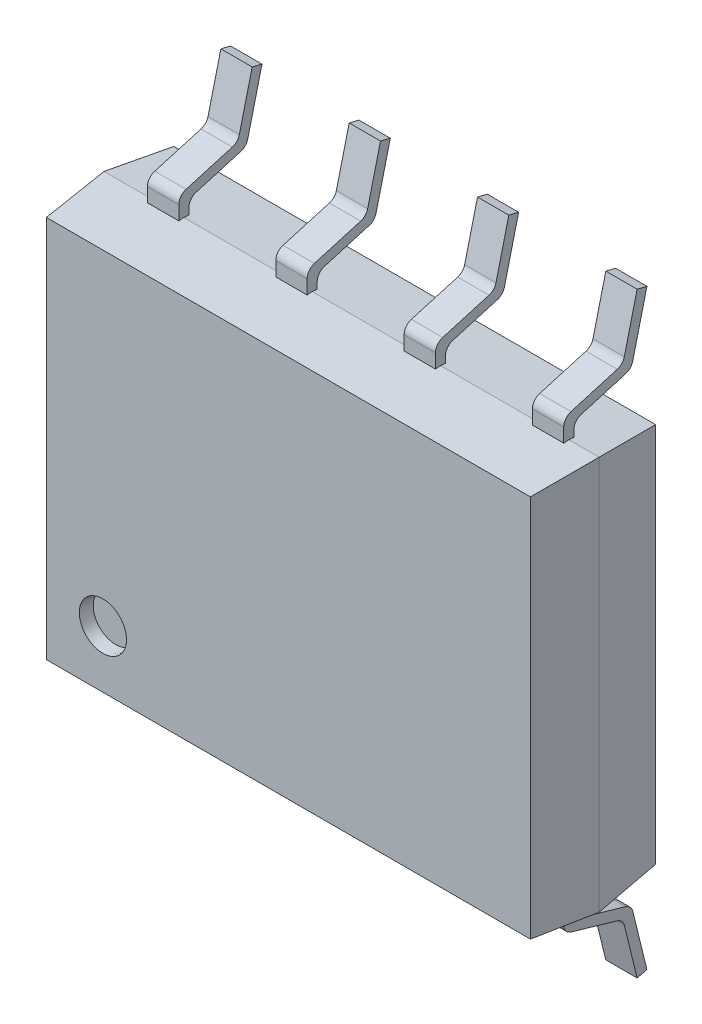
from build123d import *

# Parameters (mm, degrees)
SKETCH1_W            = 4.9
SKETCH1_H            = 3.8999999999999995
BOSS_EXTRUDE1_DEPTH  = 0.62500002
BOSS_EXTRUDE1_TAPER  = 5.000000000000003
SKETCH2_W            = 4.9
SKETCH2_H            = 3.8999999999999995
BOSS_EXTRUDE2_DEPTH  = 0.62500002
BOSS_EXTRUDE2_TAPER  = 6.000000000000002
SKETCH3_R            = 0.23364323022947278
CUT_EXTRUDE1_DEPTH   = 0.127
CUT_EXTRUDE1_DRAFT   = -5.000000000000003
EXTRUDE_THIN1_DEPTH  = 0.155
LPATTERN4_COUNT      = 4
LPATTERN4_PITCH      = 1.27
FILLET1_R            = 0.1
FILLET2_R            = 0.1
FILLET3_R            = 0.1
FILLET4_R            = 0.1
MIRROR3_COPY_1_DEPTH = 0.155
MIRROR3_COPY_2_DEPTH = 0.155
MIRROR3_COPY_3_DEPTH = 0.155
FILLET1_OF_MIRROR3_R = 0.1
FILLET2_OF_MIRROR3_R = 0.1
FILLET3_OF_MIRROR3_R = 0.1
FILLET4_OF_MIRROR3_R = 0.1


with BuildPart() as part:
    # Sketch1 → Boss-Extrude1 (new body)
    with BuildSketch(Plane.XY):
        with Locations((2.45, 1.9499999999999997)):
            Rectangle(SKETCH1_W, SKETCH1_H)
    extrude(amount=BOSS_EXTRUDE1_DEPTH, taper=BOSS_EXTRUDE1_TAPER)


with BuildPart() as body_2:
    # Sketch2 → Boss-Extrude2 (new body)
    with BuildSketch(Plane(origin=(0, 0, 0), x_dir=(-1, 0, 0), z_dir=(0, 0, -1))):
        with Locations((-2.45, 1.9499999999999997)):
            Rectangle(SKETCH2_W, SKETCH2_H)
    extrude(amount=BOSS_EXTRUDE2_DEPTH, taper=BOSS_EXTRUDE2_TAPER)


with BuildPart() as cut_extrude1_tool:
    # Sketch3 → Cut-Extrude1 (with draft: the straight prism first)
    with BuildSketch(Plane.XY.offset(0.62500002)):
        with Locations((0.6137796469189993, 0.6221262046182119)):
            Circle(SKETCH3_R)
    extrude(amount=-CUT_EXTRUDE1_DEPTH)
    # Cut-Extrude1: the draft: its side faces are tilted about the plane it starts from
    cut_extrude1_sides = [cut_extrude1_tool.faces().sort_by_distance(p)[0] for p in [
        (0.380136417, 0.622126205, 0.56150002),
    ]]
    draft(cut_extrude1_sides, Plane.XY.offset(0.62500002), CUT_EXTRUDE1_DRAFT)


with BuildPart() as part_1:
    add(part.part)

    # Cut-Extrude1: cut by cut_extrude1_tool
    add(cut_extrude1_tool.part, mode=Mode.SUBTRACT)


with BuildPart() as body_3:
    # Sketch4 → Extrude-Thin1 (new, symmetric)
    with BuildSketch(Plane(origin=(0.635, 0, 0), x_dir=(0, 0, -1), z_dir=(1, 0, 0))):
        Polygon((-0.05, 0), (-0.05, -0.30963709875086937), (0.5356753097129546, -0.47995675897337087), (0.6764487913860271, -1.0519489832234266), (0.7735512486139731, -1.0280510167765735), (0.618991733008682, -0.40004324102662947), (0.05, -0.23457531532057946), (0.05, 0), align=None)
    extrude_thin1 = extrude(amount=EXTRUDE_THIN1_DEPTH, both=True)

    # Fillet1
    fillet1_edges = [body_3.edges().sort_by_distance(p)[0] for p in [
        (0.635, -0.47995675897337087, -0.5356753097129546),
        (0.635, -0.30963709875086937, 0.05),
        (0.635, -0.23457531532057946, -0.05),
        (0.635, -0.40004324102662947, -0.618991733008682),
    ]]
    fillet(fillet1_edges, radius=FILLET1_R)


with BuildPart() as lpattern4_1:
    # LPattern4: pattern copy
    add(extrude_thin1.moved(Location(Vector(1, 0, 0) * (1 * LPATTERN4_PITCH))))

    # Fillet2
    fillet2_edges = [lpattern4_1.edges().sort_by_distance(p)[0] for p in [
        (1.905, -0.47995675897337087, -0.5356753097129546),
        (1.905, -0.30963709875086937, 0.05),
        (1.905, -0.23457531532057946, -0.05),
        (1.905, -0.40004324102662947, -0.618991733008682),
    ]]
    fillet(fillet2_edges, radius=FILLET2_R)


with BuildPart() as lpattern4_2:
    # LPattern4: pattern copy
    add(extrude_thin1.moved(Location(Vector(1, 0, 0) * (2 * LPATTERN4_PITCH))))

    # Fillet3
    fillet3_edges = [lpattern4_2.edges().sort_by_distance(p)[0] for p in [
        (3.175, -0.47995675897337087, -0.5356753097129546),
        (3.175, -0.30963709875086937, 0.05),
        (3.175, -0.23457531532057946, -0.05),
        (3.175, -0.40004324102662947, -0.618991733008682),
    ]]
    fillet(fillet3_edges, radius=FILLET3_R)


with BuildPart() as lpattern4_3:
    # LPattern4: pattern copy
    add(extrude_thin1.moved(Location(Vector(1, 0, 0) * (3 * LPATTERN4_PITCH))))

    # Fillet4
    fillet4_edges = [lpattern4_3.edges().sort_by_distance(p)[0] for p in [
        (4.445, -0.47995675897337087, -0.5356753097129546),
        (4.445, -0.30963709875086937, 0.05),
        (4.445, -0.23457531532057946, -0.05),
        (4.445, -0.40004324102662947, -0.618991733008682),
    ]]
    fillet(fillet4_edges, radius=FILLET4_R)


with BuildPart() as part_2:
    add(part_1.part)

    add(body_2.part)  # Mirror3 merges body 2
    # Mirror3: Extrude-Thin1 across plane
    add(extrude_thin1.mirror(Plane.ZX.offset(1.9000000099999999)))

    # Mirror3 copy 1 sketch → Mirror3 copy 1 (add, symmetric)
    with BuildSketch(Plane(origin=(1.905, 3.8000000199999997, 0), x_dir=(0, 0, -1), z_dir=(1, 0, 0))):
        Polygon((-0.05, 0), (-0.05, 0.30963709875086937), (0.5356753097129546, 0.47995675897337087), (0.6764487913860271, 1.0519489832234266), (0.7735512486139731, 1.0280510167765735), (0.618991733008682, 0.40004324102662947), (0.05, 0.23457531532057946), (0.05, 0), align=None)
    extrude(amount=MIRROR3_COPY_1_DEPTH, both=True)

    # Mirror3 copy 2 sketch → Mirror3 copy 2 (add, symmetric)
    with BuildSketch(Plane(origin=(3.175, 3.8000000199999997, 0), x_dir=(0, 0, -1), z_dir=(1, 0, 0))):
        Polygon((-0.05, 0), (-0.05, 0.30963709875086937), (0.5356753097129546, 0.47995675897337087), (0.6764487913860271, 1.0519489832234266), (0.7735512486139731, 1.0280510167765735), (0.618991733008682, 0.40004324102662947), (0.05, 0.23457531532057946), (0.05, 0), align=None)
    extrude(amount=MIRROR3_COPY_2_DEPTH, both=True)

    # Mirror3 copy 3 sketch → Mirror3 copy 3 (add, symmetric)
    with BuildSketch(Plane(origin=(4.445, 3.8000000199999997, 0), x_dir=(0, 0, -1), z_dir=(1, 0, 0))):
        Polygon((-0.05, 0), (-0.05, 0.30963709875086937), (0.5356753097129546, 0.47995675897337087), (0.6764487913860271, 1.0519489832234266), (0.7735512486139731, 1.0280510167765735), (0.618991733008682, 0.40004324102662947), (0.05, 0.23457531532057946), (0.05, 0), align=None)
    extrude(amount=MIRROR3_COPY_3_DEPTH, both=True)

    # Fillet1 of Mirror3
    fillet1_of_mirror3_edges = [part_2.edges().sort_by_distance(p)[0] for p in [
        (0.635, 4.279956778973371, -0.5356753097129546),
        (0.635, 4.109637118750869, 0.05),
        (0.635, 4.0345753353205795, -0.05),
        (0.635, 4.200043261026629, -0.618991733008682),
    ]]
    fillet(fillet1_of_mirror3_edges, radius=FILLET1_OF_MIRROR3_R)

    # Fillet2 of Mirror3
    fillet2_of_mirror3_edges = [part_2.edges().sort_by_distance(p)[0] for p in [
        (1.905, 4.279956778973371, -0.5356753097129546),
        (1.905, 4.109637118750869, 0.05),
        (1.905, 4.0345753353205795, -0.05),
        (1.905, 4.200043261026629, -0.618991733008682),
    ]]
    fillet(fillet2_of_mirror3_edges, radius=FILLET2_OF_MIRROR3_R)

    # Fillet3 of Mirror3
    fillet3_of_mirror3_edges = [part_2.edges().sort_by_distance(p)[0] for p in [
        (3.175, 4.279956778973371, -0.5356753097129546),
        (3.175, 4.109637118750869, 0.05),
        (3.175, 4.0345753353205795, -0.05),
        (3.175, 4.200043261026629, -0.618991733008682),
    ]]
    fillet(fillet3_of_mirror3_edges, radius=FILLET3_OF_MIRROR3_R)

    # Fillet4 of Mirror3
    fillet4_of_mirror3_edges = [part_2.edges().sort_by_distance(p)[0] for p in [
        (4.445, 4.279956778973371, -0.5356753097129546),
        (4.445, 4.109637118750869, 0.05),
        (4.445, 4.0345753353205795, -0.05),
        (4.445, 4.200043261026629, -0.618991733008682),
    ]]
    fillet(fillet4_of_mirror3_edges, radius=FILLET4_OF_MIRROR3_R)


solid = Compound([body_3.part, lpattern4_1.part, lpattern4_2.part, lpattern4_3.part, part_2.part])
